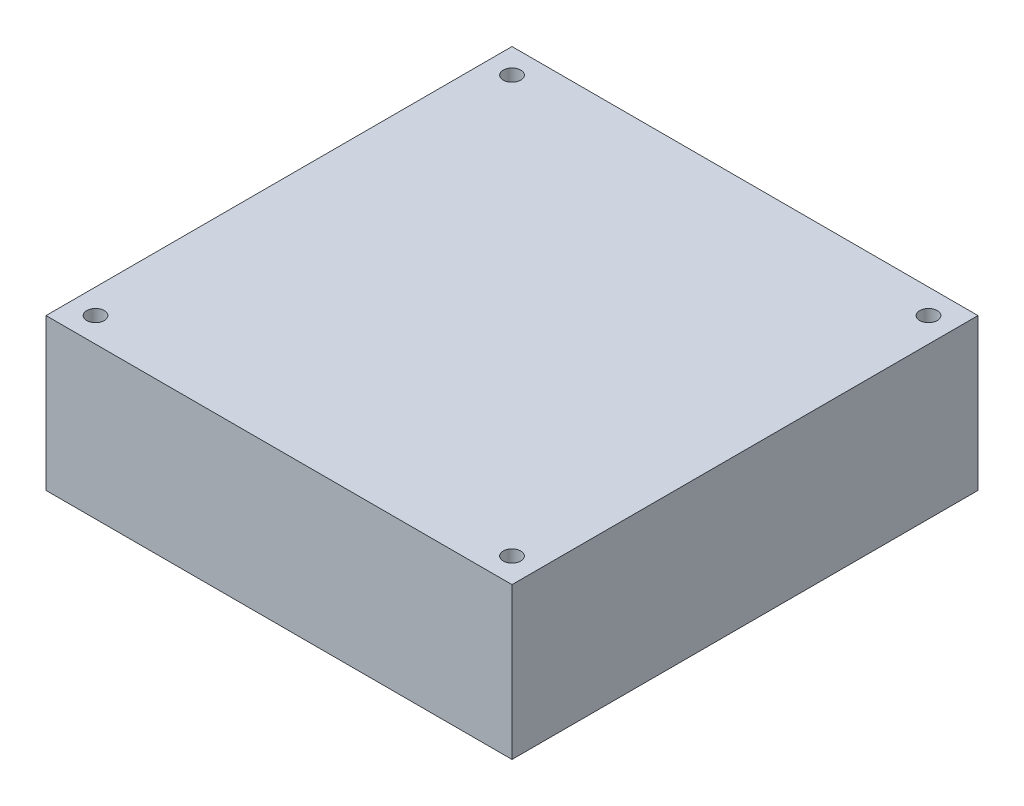
from build123d import *

# Parameters (mm, degrees)
SKETCH1_W           = 80
SKETCH1_H           = 80
SKETCH1_R           = 1.5
BOSS_EXTRUDE1_DEPTH = 26


with BuildPart() as part:
    # Sketch1 → Boss-Extrude1 (new body)
    with BuildSketch(Plane(origin=(0, 0, 0), x_dir=(1, 0, 0), z_dir=(0, 1, 0))):
        Rectangle(SKETCH1_W, SKETCH1_H)
        with Locations((35.75, 35.75)):
            Circle(SKETCH1_R, mode=Mode.SUBTRACT)
        with Locations((-35.75, 35.75)):
            Circle(SKETCH1_R, mode=Mode.SUBTRACT)
        with Locations((-35.75, -35.75)):
            Circle(SKETCH1_R, mode=Mode.SUBTRACT)
        with Locations((35.75, -35.75)):
            Circle(SKETCH1_R, mode=Mode.SUBTRACT)
    extrude(amount=BOSS_EXTRUDE1_DEPTH)


solid = part.part
